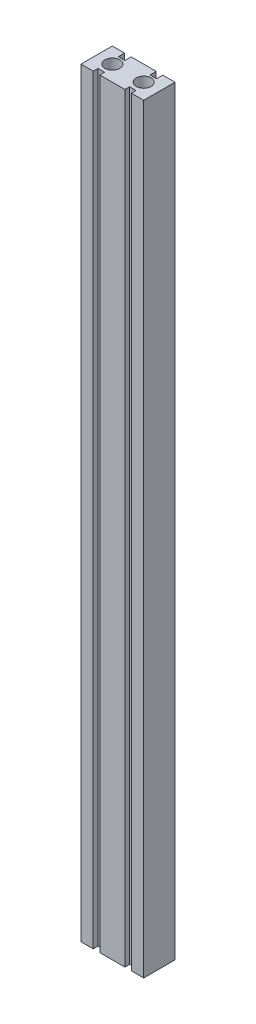
from build123d import *

# Parameters (mm, degrees)
SKETCH_2_W          = 40
SKETCH_2_H          = 20
EXTRUDE_1_DEPTH     = 485
SKETCH_3_R          = 4.75
CUT_EXTRUDE_1_DEPTH = 486
SKETCH_4_W          = 4.2
SKETCH_4_H          = 485
CUT_EXTRUDE_2_DEPTH = 3
SKETCH_5_W          = 4.2
SKETCH_5_H          = 485
CUT_EXTRUDE_3_DEPTH = 4


with BuildPart() as part:
    # 草图2 → 凸台-拉伸1 (new body)
    with BuildSketch(Plane(origin=(0, 0, 0), x_dir=(1, 0, 0), z_dir=(0, 1, 0))):
        Rectangle(SKETCH_2_W, SKETCH_2_H)
    extrude(amount=EXTRUDE_1_DEPTH)

    # 草图3 → 切除-拉伸1 (cut, through all)
    with BuildSketch(Plane.XZ):
        with Locations((-10, 0)):
            Circle(SKETCH_3_R)
        with Locations((10, 0)):
            Circle(SKETCH_3_R)
    extrude(amount=-CUT_EXTRUDE_1_DEPTH, mode=Mode.SUBTRACT)

    # 草图4 → 切除-拉伸2 (cut)
    with BuildSketch(Plane.XY.offset(10)):
        with Locations((-10.1, 242.5)):
            Rectangle(SKETCH_4_W, SKETCH_4_H)
        with Locations((10.1, 242.5)):
            Rectangle(SKETCH_4_W, SKETCH_4_H)
    extrude(amount=-CUT_EXTRUDE_2_DEPTH, mode=Mode.SUBTRACT)

    # 草图5 → 切除-拉伸3 (cut)
    with BuildSketch(Plane(origin=(0, 0, -10), x_dir=(-1, 0, 0), z_dir=(0, 0, -1))):
        with Locations((-10.1, 242.5)):
            Rectangle(SKETCH_5_W, SKETCH_5_H)
        with Locations((10.1, 242.5)):
            Rectangle(SKETCH_5_W, SKETCH_5_H)
    extrude(amount=-CUT_EXTRUDE_3_DEPTH, mode=Mode.SUBTRACT)


solid = part.part
